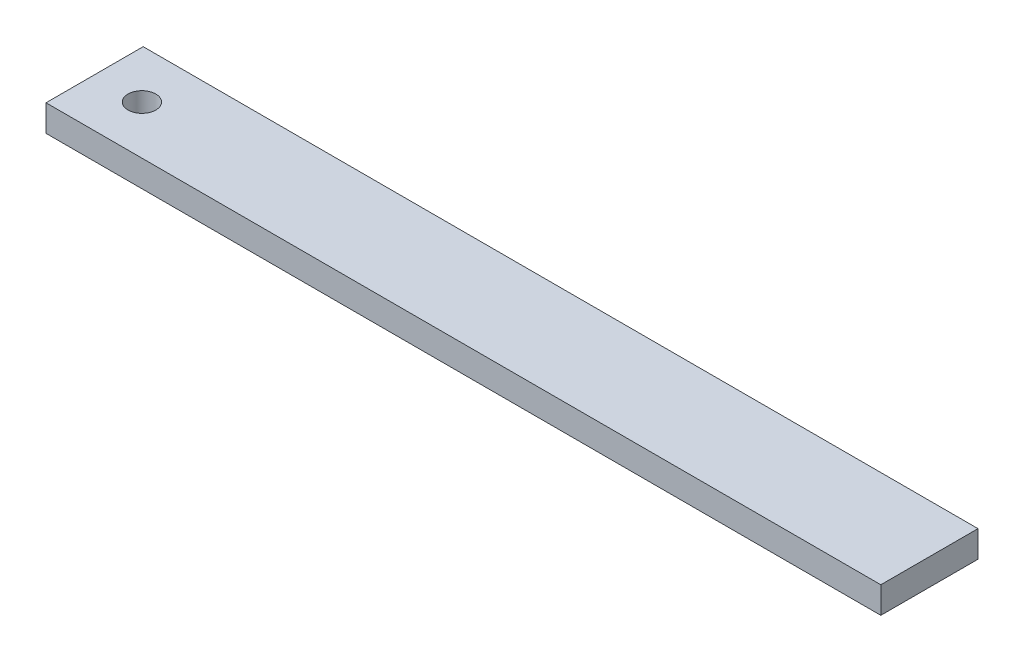
from build123d import *

# Parameters (mm, degrees)
SKETCH1_W           = 300
SKETCH1_H           = 34.925
SKETCH1_R           = 5
BOSS_EXTRUDE1_DEPTH = 9.525


with BuildPart() as part:
    # Sketch1 → Boss-Extrude1 (new body)
    with BuildSketch(Plane(origin=(0, 0, 0), x_dir=(1, 0, 0), z_dir=(0, 1, 0))):
        with Locations((-150, 17.4625)):
            Rectangle(SKETCH1_W, SKETCH1_H)
        with Locations((-283, 17.4625)):
            Circle(SKETCH1_R, mode=Mode.SUBTRACT)
    extrude(amount=BOSS_EXTRUDE1_DEPTH)


solid = part.part
